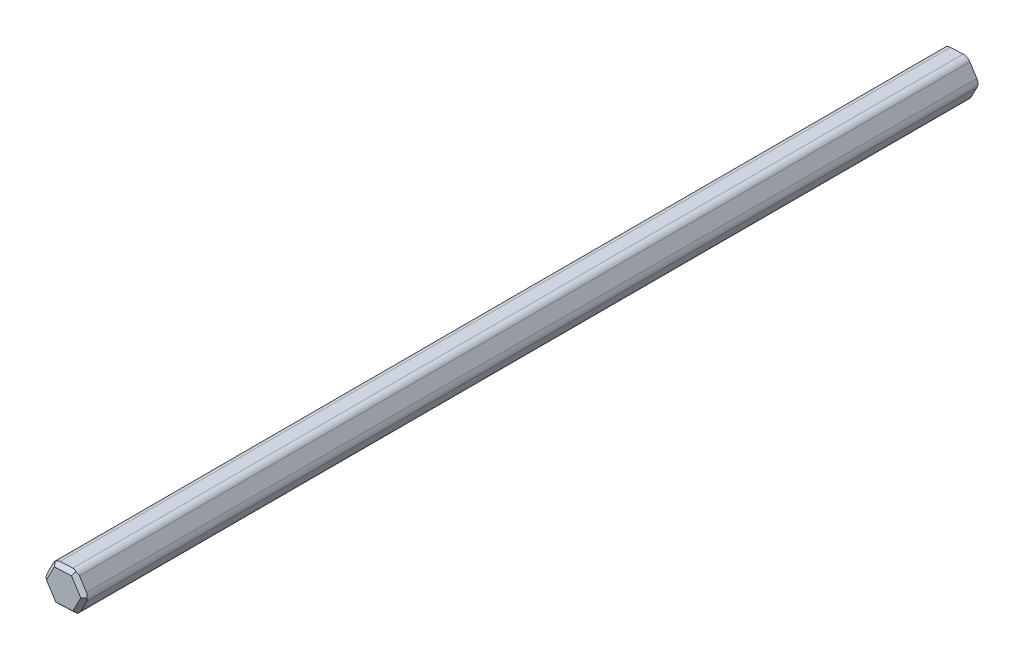
from build123d import *

# Parameters (mm, degrees)
BOSS_EXTRUDE1_DEPTH = 60.96
CHAMFER1_SIZE       = 0.254
FILLET1_R           = 0.508


with BuildPart() as part:
    # Sketch1 → Boss-Extrude1 (new body)
    with BuildSketch(Plane.XY):
        Polygon((-0.791369427, 1.234612394), (-1.464890411, -0.06803983), (-0.673520984, -1.302652224), (0.791369427, -1.234612394), (1.464890411, 0.06803983), (0.673520984, 1.302652224), align=None)
    extrude(amount=BOSS_EXTRUDE1_DEPTH)

    # Chamfer1
    chamfer1_edges = [part.edges().sort_by_distance(p)[0] for p in [
        (-1.069205697, -0.685346027, 60.96),
        (0.058924221, -1.268632309, 60.96),
        (1.128129919, -0.583286282, 60.96),
        (1.069205697, 0.685346027, 60.96),
        (-0.058924221, 1.268632309, 60.96),
        (-1.128129919, 0.583286282, 60.96),
    ]]
    chamfer(chamfer1_edges, length=CHAMFER1_SIZE)

    # Fillet1
    fillet1_edges = [part.edges().sort_by_distance(p)[0] for p in [
        (-0.673520984, -1.302652224, 30.353),
        (-1.464890411, -0.06803983, 30.353),
        (0.791369427, -1.234612394, 30.353),
        (1.464890411, 0.06803983, 30.353),
        (0.673520984, 1.302652224, 30.353),
        (-0.791369427, 1.234612394, 30.353),
    ]]
    fillet(fillet1_edges, radius=FILLET1_R)


solid = part.part
